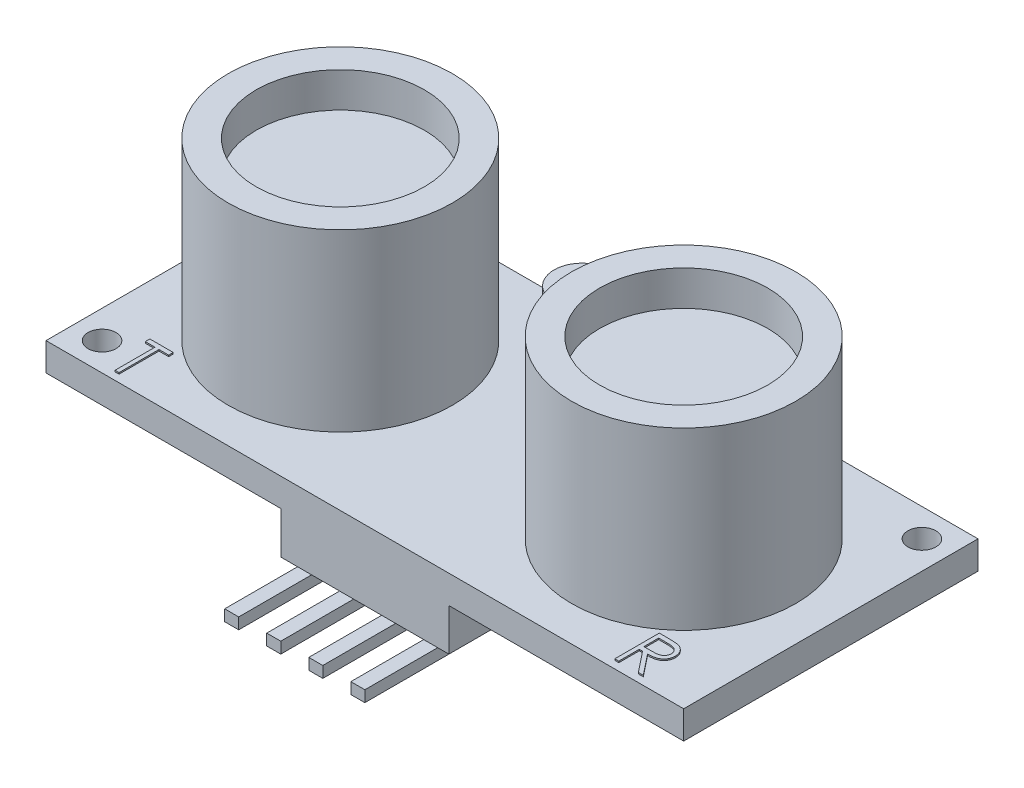
from build123d import *

# Parameters (mm, degrees)
SKETCH2_W            = 45.5
SKETCH2_H            = 21
BOSS_EXTRUDE2_DEPTH  = 2
SKETCH4_R            = 8
BOSS_EXTRUDE3_DEPTH  = 12.5
SKETCH5_R            = 6
CUT_EXTRUDE1_DEPTH   = 2.5
BOSS_EXTRUDE5_DEPTH  = 4
SKETCH7_W            = 6
SKETCH7_H            = 3
BOSS_EXTRUDE6_DEPTH  = 3
SKETCH8_W            = 1
SKETCH8_H            = 1
BOSS_EXTRUDE7_DEPTH  = 1
SKETCH10_W           = 1
SKETCH10_H           = 0.8
BOSS_EXTRUDE8_DEPTH  = 6
SKETCH11_R           = 1
CUT_EXTRUDE2_DEPTH   = 15.5
BOSS_EXTRUDE10_DEPTH = 0.1


with BuildPart() as part:
    # Sketch2 → Boss-Extrude2 (new body)
    with BuildSketch(Plane(origin=(0, 0, 0), x_dir=(1, 0, 0), z_dir=(0, 1, 0))):
        with Locations((-22.75, 10.5)):
            Rectangle(SKETCH2_W, SKETCH2_H)
    extrude(amount=BOSS_EXTRUDE2_DEPTH)

    # Sketch4 → Boss-Extrude3 (add)
    with BuildSketch(Plane(origin=(0, 2, 0), x_dir=(1, 0, 0), z_dir=(0, 1, 0))):
        with Locations((-35, 10.5)):
            Circle(SKETCH4_R)
        with Locations((-10.5, 10.5)):
            Circle(SKETCH4_R)
    extrude(amount=BOSS_EXTRUDE3_DEPTH)

    # Sketch5 → Cut-Extrude1 (cut)
    with BuildSketch(Plane(origin=(0, 14.5, 0), x_dir=(1, 0, 0), z_dir=(0, 1, 0))):
        with Locations((-35, 10.5)):
            Circle(SKETCH5_R)
        with Locations((-10.5, 10.5)):
            Circle(SKETCH5_R)
    extrude(amount=-CUT_EXTRUDE1_DEPTH, mode=Mode.SUBTRACT)

    # Sketch6 → Boss-Extrude5 (add)
    with BuildSketch(Plane(origin=(0, 2, 0), x_dir=(1, 0, 0), z_dir=(0, 1, 0))):
        with BuildLine():
            Line((-25.75, 20.493953902), (-19.75, 20.493953902))
            ThreePointArc((-19.75, 20.493953902), (-17.756046098, 18.5), (-19.75, 16.506046098))
            Line((-19.75, 16.506046098), (-25.75, 16.506046098))
            ThreePointArc((-25.75, 16.506046098), (-27.743953902, 18.5), (-25.75, 20.493953902))
        make_face()
    extrude(amount=BOSS_EXTRUDE5_DEPTH)

    # Sketch7 → Boss-Extrude6 (add)
    with BuildSketch(Plane.XZ):
        with Locations((-19.75, -1.5)):
            Rectangle(SKETCH7_W, SKETCH7_H)
        with Locations((-25.75, -1.5)):
            Rectangle(SKETCH7_W, SKETCH7_H)
    extrude(amount=BOSS_EXTRUDE6_DEPTH)

    # Sketch8 → Boss-Extrude7 (add)
    with BuildSketch(Plane.XZ.offset(3)):
        with Locations((-24.25, -1.5)):
            Rectangle(SKETCH8_W, SKETCH8_H)
        with Locations((-21.25, -1.5)):
            Rectangle(SKETCH8_W, SKETCH8_H)
        with Locations((-18.25, -1.5)):
            Rectangle(SKETCH8_W, SKETCH8_H)
        with Locations((-27.25, -1.5)):
            Rectangle(SKETCH8_W, SKETCH8_H)
    extrude(amount=BOSS_EXTRUDE7_DEPTH)

    # Sketch10 → Boss-Extrude8 (add)
    with BuildSketch(Plane.XY.offset(-1)):
        with Locations((-18.25, -3.6)):
            Rectangle(SKETCH10_W, SKETCH10_H)
        with Locations((-21.25, -3.6)):
            Rectangle(SKETCH10_W, SKETCH10_H)
        with Locations((-24.25, -3.6)):
            Rectangle(SKETCH10_W, SKETCH10_H)
        with Locations((-27.25, -3.6)):
            Rectangle(SKETCH10_W, SKETCH10_H)
    extrude(amount=BOSS_EXTRUDE8_DEPTH)

    # Sketch11 → Cut-Extrude2 (cut, through all)
    with BuildSketch(Plane.XZ):
        with Locations((-2, -19)):
            Circle(SKETCH11_R)
        with Locations((-43.5, -2)):
            Circle(SKETCH11_R)
    extrude(amount=-CUT_EXTRUDE2_DEPTH, mode=Mode.SUBTRACT)

    # Sketch15 → Boss-Extrude10 (add)
    with BuildSketch(Plane(origin=(0, 2, 0), x_dir=(1, 0, 0), z_dir=(0, 1, 0))):
        Polygon((-41.795833333, 3.38023745), (-41.795833333, 3.705878476), (-40.126923077, 3.705878476), (-40.126923077, 3.38023745), (-40.818910256, 3.38023745), (-40.818910256, 0.530878476), (-41.103846154, 0.530878476), (-41.103846154, 3.38023745), align=None)
        with BuildLine():
            Line((-5.446153846, 3.705878476), (-4.810772236, 3.705878476))
            add(Edge.make_bspline(
                [(-4.810772236, 3.705878476), (-4.768371355, 3.705737337), (-4.686956967, 3.705466335), (-4.570322643, 3.70395525), (-4.464343776, 3.699624228), (-4.369075779, 3.695897155), (-4.284520399, 3.689100894), (-4.210418357, 3.682605164), (-4.147110946, 3.674101915), (-4.108787923, 3.666204853), (-4.091436298, 3.662629277)],
                knots=[0, 0, 0, 0, 0.000127205, 0.000244248, 0.000349896, 0.000445402, 0.000530231, 0.00060434, 0.000668562, 0.000721699, 0.000721699, 0.000721699, 0.000721699], degree=3))
            add(Edge.make_bspline(
                [(-4.091436298, 3.662629277), (-4.068207432, 3.656889997), (-4.022245234, 3.645533872), (-3.956069103, 3.621531234), (-3.893009681, 3.59375486), (-3.833328911, 3.561130628), (-3.777325729, 3.523416363), (-3.72442269, 3.481263138), (-3.674379734, 3.434901601), (-3.629220684, 3.383162852), (-3.586640258, 3.32888259), (-3.550727719, 3.270187039), (-3.519770126, 3.208808368), (-3.495122586, 3.144122353), (-3.475276139, 3.076756317), (-3.461282336, 3.006100052), (-3.452890187, 2.932475453), (-3.452035789, 2.882257921), (-3.451602564, 2.856794942)],
                knots=[0, 0, 0, 0, 7.1738e-05, 0.000141945, 0.000210849, 0.000278309, 0.000345694, 0.000413139, 0.000481086, 0.000550014, 0.000618962, 0.000687796, 0.000756061, 0.000824921, 0.000895163, 0.000966511, 0.001040751, 0.001117115, 0.001117115, 0.001117115, 0.001117115], degree=3))
            add(Edge.make_bspline(
                [(-3.451602564, 2.856794942), (-3.452935155, 2.81449024), (-3.455535386, 2.731942809), (-3.479778873, 2.612144724), (-3.51949043, 2.500394417), (-3.574212271, 2.396832596), (-3.643898509, 2.303477939), (-3.727650284, 2.221480883), (-3.825514317, 2.152864676), (-3.916618054, 2.105282489), (-3.997094506, 2.074808922), (-4.063346155, 2.053367368), (-4.135615484, 2.036801157), (-4.213210066, 2.02196018), (-4.296452811, 2.010755429), (-4.385144204, 2.002548875), (-4.479347498, 1.997419845), (-4.544062226, 1.996656027), (-4.577353766, 1.996263091)],
                knots=[0, 0, 0, 0, 0.000126797, 0.000247415, 0.000364897, 0.000481551, 0.000597433, 0.000713022, 0.000831615, 0.000954788, 0.001020224, 0.001089619, 0.001163513, 0.001242474, 0.001326575, 0.001415367, 0.001509635, 0.001609508, 0.001609508, 0.001609508, 0.001609508], degree=3))
            Line((-4.577353766, 1.996263091), (-3.410897436, 0.530878476))
            Line((-3.410897436, 0.530878476), (-3.763251202, 0.530878476))
            Line((-3.763251202, 0.530878476), (-4.929707532, 1.996263091))
            Line((-4.929707532, 1.996263091), (-5.161217949, 1.996263091))
            Line((-5.161217949, 1.996263091), (-5.161217949, 0.530878476))
            Line((-5.161217949, 0.530878476), (-5.446153846, 0.530878476))
            Line((-5.446153846, 0.530878476), (-5.446153846, 3.705878476))
        make_face()
        with BuildLine():
            Line((-5.161217949, 3.38023745), (-5.161217949, 2.321904117))
            Line((-5.161217949, 2.321904117), (-4.579897837, 2.317451994))
            add(Edge.make_bspline(
                [(-4.579897837, 2.317451994), (-4.552756087, 2.317439986), (-4.500147646, 2.317416712), (-4.424037757, 2.321039638), (-4.353171656, 2.325161076), (-4.287820402, 2.331465125), (-4.227954802, 2.339589562), (-4.173604777, 2.349752269), (-4.124681608, 2.361592354), (-4.067623648, 2.379918115), (-4.003909081, 2.408952146), (-3.934665542, 2.451193705), (-3.875699136, 2.504324263), (-3.825880789, 2.565078756), (-3.785849091, 2.631877353), (-3.757626013, 2.703919345), (-3.739716797, 2.779386009), (-3.737604474, 2.831254721), (-3.736538462, 2.85743096)],
                knots=[0, 0, 0, 0, 8.1413e-05, 0.000157801, 0.000228539, 0.000294357, 0.000354712, 0.000409723, 0.000460165, 0.000505621, 0.000589315, 0.00066961, 0.000747992, 0.000826171, 0.000904597, 0.000980539, 0.001057529, 0.001135968, 0.001135968, 0.001135968, 0.001135968], degree=3))
            add(Edge.make_bspline(
                [(-3.736538462, 2.85743096), (-3.737628957, 2.882963923), (-3.739789921, 2.93356094), (-3.757432733, 3.007634515), (-3.7872681, 3.077545249), (-3.827474702, 3.143008746), (-3.876459649, 3.202431806), (-3.933897951, 3.253274581), (-3.998219092, 3.295229452), (-4.058336537, 3.322039498), (-4.112070429, 3.338476793), (-4.158724478, 3.35004392), (-4.21143989, 3.359337117), (-4.270472627, 3.366783001), (-4.335570678, 3.373182843), (-4.407063197, 3.377493385), (-4.484475848, 3.380045962), (-4.538130564, 3.380172135), (-4.565905449, 3.38023745)],
                knots=[0, 0, 0, 0, 7.6536e-05, 0.000151667, 0.000226914, 0.000303706, 0.000381394, 0.000457083, 0.00053294, 0.00061095, 0.000653596, 0.000701416, 0.000755061, 0.00081407, 0.000879888, 0.000951261, 0.001028897, 0.001112218, 0.001112218, 0.001112218, 0.001112218], degree=3))
            Line((-4.565905449, 3.38023745), (-5.161217949, 3.38023745))
        make_face(mode=Mode.SUBTRACT)
    extrude(amount=BOSS_EXTRUDE10_DEPTH)


solid = part.part
